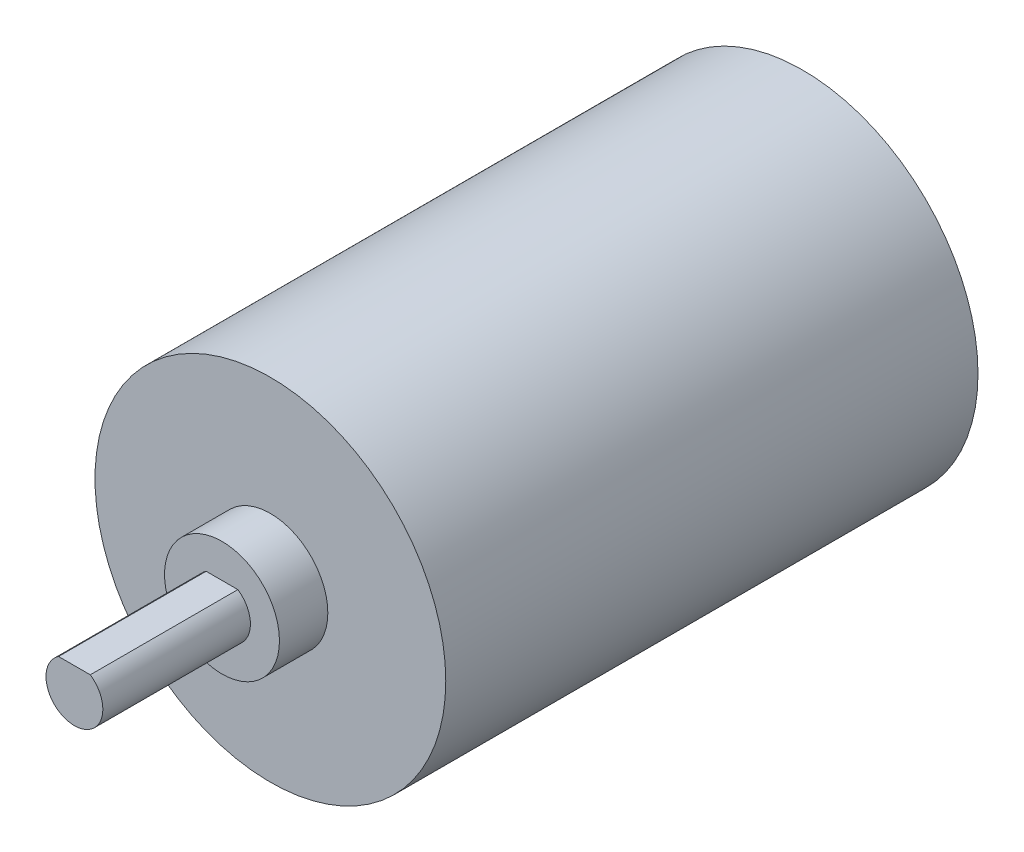
from build123d import *

# Parameters (mm, degrees)
SKETCH1_R           = 18.415
BOSS_EXTRUDE1_DEPTH = 55.88
SKETCH1_3_R         = 6.0325
BOSS_EXTRUDE2_DEPTH = 5.08
BOSS_EXTRUDE3_DEPTH = 15.494


with BuildPart() as part:
    # Sketch1 → Boss-Extrude1 (new body)
    with BuildSketch(Plane.XY):
        Circle(SKETCH1_R)
    extrude(amount=-BOSS_EXTRUDE1_DEPTH)

    # Sketch1_3 → Boss-Extrude2 (add)
    with BuildSketch(Plane.XY):
        Circle(SKETCH1_3_R)
    extrude(amount=BOSS_EXTRUDE2_DEPTH)

    # Sketch3 → Boss-Extrude3 (add)
    with BuildSketch(Plane.XY.offset(5.08)):
        with BuildLine():
            Line((-1.665589385, 2.4765), (1.665589385, 2.4765))
            ThreePointArc((1.665589385, 2.4765), (0, -2.9845), (-1.665589385, 2.4765))
        make_face()
    extrude(amount=BOSS_EXTRUDE3_DEPTH)


solid = part.part
